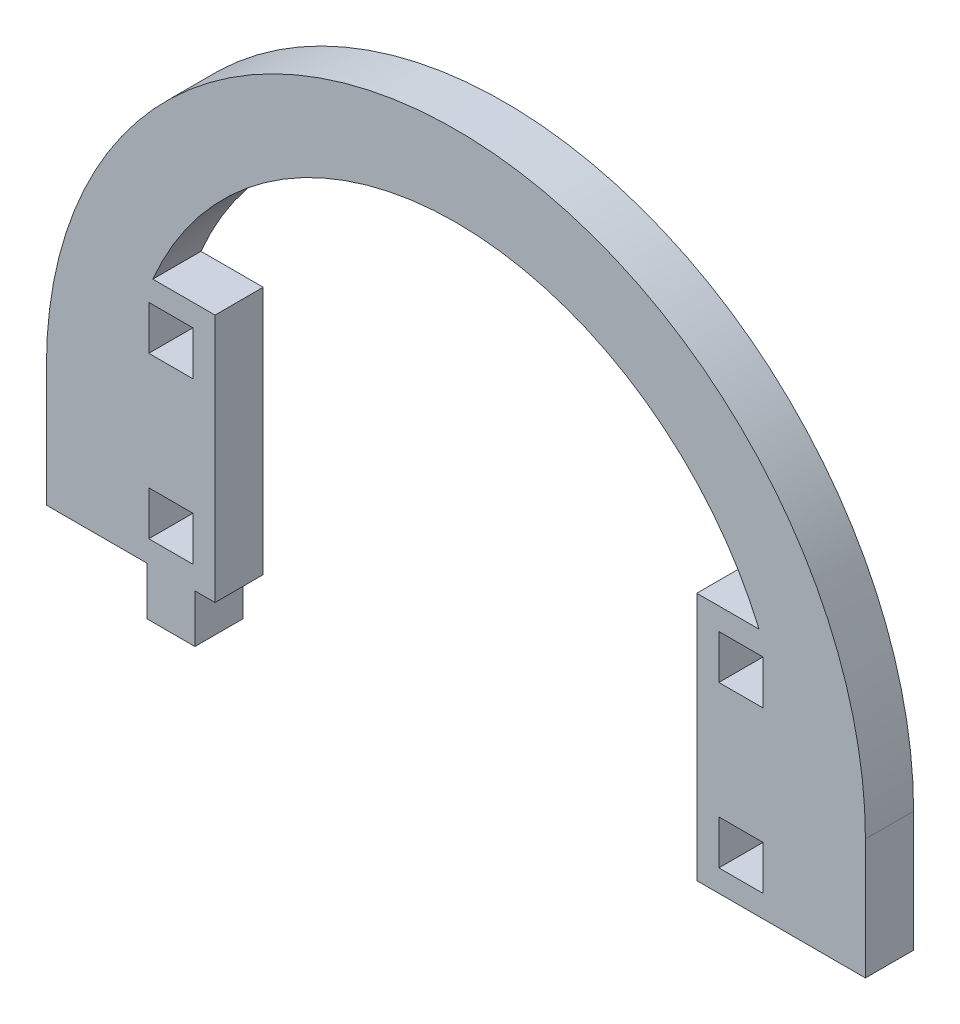
from build123d import *

# Parameters (mm, degrees)
MODEL_W             = 5.5
MODEL_H             = 5.5
BOSS_EXTRUDE1_DEPTH = 6


with BuildPart() as part:
    # Model → Boss-Extrude1 (new body)
    with BuildSketch(Plane.XY):
        with BuildLine():
            Line((3055.225160199, 1463.457958964), (3055.225160199, 1448.457958964))
            Line((3055.225160199, 1448.457958964), (3067.725160199, 1448.457958964))
            Line((3067.725160199, 1448.457958964), (3067.725160199, 1442.457958964))
            Line((3067.725160199, 1442.457958964), (3073.725160199, 1442.457958964))
            Line((3073.725160199, 1442.457958964), (3073.725160199, 1448.457958964))
            Line((3073.725160199, 1448.457958964), (3076.225160199, 1448.457958964))
            Line((3076.225160199, 1448.457958964), (3076.225160199, 1479.457958964))
            Line((3076.225160199, 1479.457958964), (3068.475988022, 1479.457958964))
            ThreePointArc((3068.475988022, 1479.457958964), (3106.225160199, 1504.457958964), (3143.974332375, 1479.457958964))
            Line((3143.974332375, 1479.457958964), (3136.225160199, 1479.457958964))
            Line((3136.225160199, 1479.457958964), (3136.225160199, 1448.457958964))
            Line((3136.225160199, 1448.457958964), (3147.225160199, 1448.457958964))
            Line((3147.225160199, 1448.457958964), (3157.225160199, 1448.457958964))
            Line((3157.225160199, 1448.457958964), (3157.225160199, 1463.457958964))
            ThreePointArc((3157.225160199, 1463.457958964), (3106.225160199, 1514.457958964), (3055.225160199, 1463.457958964))
        make_face()
        with Locations((3141.725160199, 1453.957958964)):
            Rectangle(MODEL_W, MODEL_H, mode=Mode.SUBTRACT)
        with Locations((3141.725160199, 1473.957958964)):
            Rectangle(MODEL_W, MODEL_H, mode=Mode.SUBTRACT)
        with Locations((3070.725160199, 1453.957958964)):
            Rectangle(MODEL_W, MODEL_H, mode=Mode.SUBTRACT)
        with Locations((3070.725160199, 1473.957958964)):
            Rectangle(MODEL_W, MODEL_H, mode=Mode.SUBTRACT)
    extrude(amount=BOSS_EXTRUDE1_DEPTH)


solid = part.part
